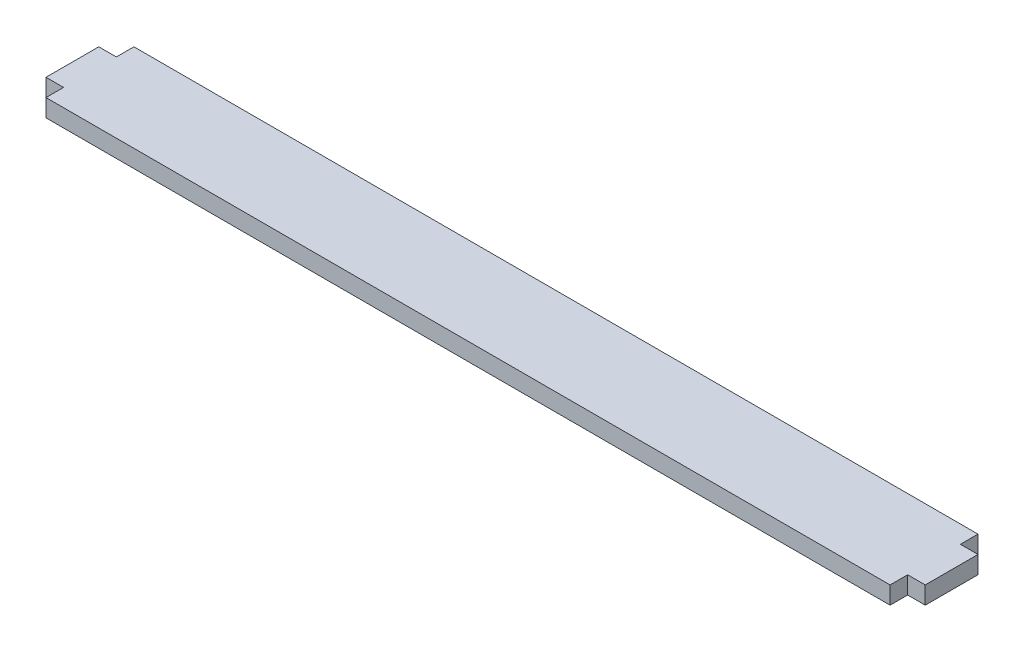
from build123d import *

# Parameters (mm, degrees)
BOSS_EXTRUDE1_DEPTH = 3.175


with BuildPart() as part:
    # Sketch1 → Boss-Extrude1 (new body)
    with BuildSketch(Plane(origin=(0, 0, 0), x_dir=(1, 0, 0), z_dir=(0, 1, 0))):
        Polygon((-76.2, -7.9375), (76.2, -7.9375), (76.2, -4.7625), (79.375, -4.7625), (79.375, 4.7625), (76.2, 4.7625), (76.2, 7.9375), (-76.2, 7.9375), (-76.2, 4.7625), (-79.375, 4.7625), (-79.375, -4.7625), (-76.2, -4.7625), align=None)
    extrude(amount=BOSS_EXTRUDE1_DEPTH)


solid = part.part
